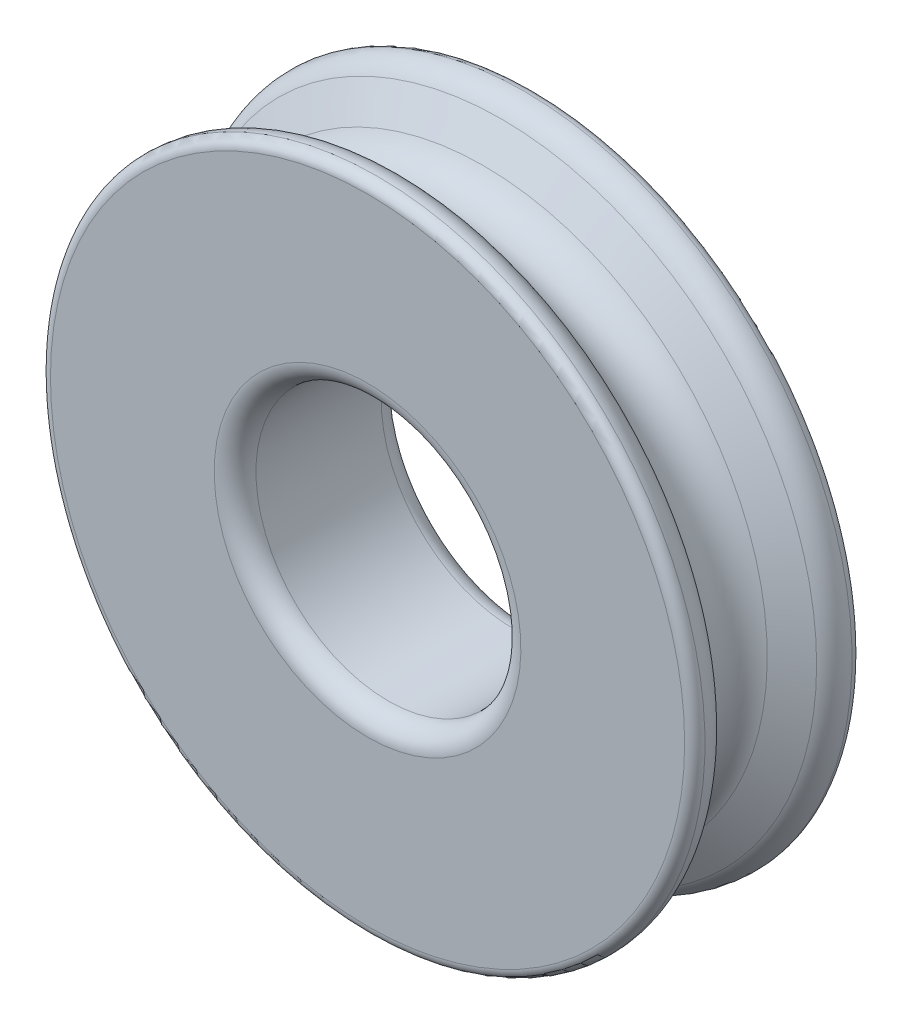
from build123d import *

# Parameters (mm, degrees)
SKETCH2_R          = 6.35
CUT_EXTRUDE2_DEPTH = 9.0000094
FILLET3_R          = 1


with BuildPart() as part:
    # Sketch1 → Revolve1 (revolve)
    with BuildSketch(Plane(origin=(0, 0, 0), x_dir=(0, 0, -1), z_dir=(1, 0, 0))):
        with BuildLine():
            Line((4.0000047, 0), (-4.0000047, 0))
            Line((-4.0000047, 0), (-4.0000047, 15.200621907))
            ThreePointArc((-4.0000047, 15.200621907), (-3.862299847, 15.545211447), (-3.525035946, 15.699994))
            ThreePointArc((-3.525035946, 15.699994), (-2.891173009, 15.55542644), (-2.425734949, 15.101499778))
            Line((-2.425734949, 15.101499778), (-1.558842609, 13.5999982))
            ThreePointArc((-1.558842609, 13.5999982), (0, 12.7), (1.558842609, 13.5999982))
            Line((1.558842609, 13.5999982), (2.425734949, 15.101499778))
            ThreePointArc((2.425734949, 15.101499778), (2.891173009, 15.55542644), (3.525035946, 15.699994))
            ThreePointArc((3.525035946, 15.699994), (3.862299847, 15.545211447), (4.0000047, 15.200621907))
            Line((4.0000047, 15.200621907), (4.0000047, 0))
        make_face()
    revolve(axis=Axis((0, 0, -4.0000047), (0, 0, 1)))

    # Sketch2 → Cut-Extrude2 (cut, through all)
    with BuildSketch(Plane.XY.offset(4.0000047)):
        Circle(SKETCH2_R)
    extrude(amount=-CUT_EXTRUDE2_DEPTH, mode=Mode.SUBTRACT)

    # Fillet3
    fillet3_edges = [part.edges().sort_by_distance(p)[0] for p in [
        (-6.35, 0, -4.0000047),
        (-6.35, 0, 4.0000047),
    ]]
    fillet(fillet3_edges, radius=FILLET3_R)


solid = part.part
